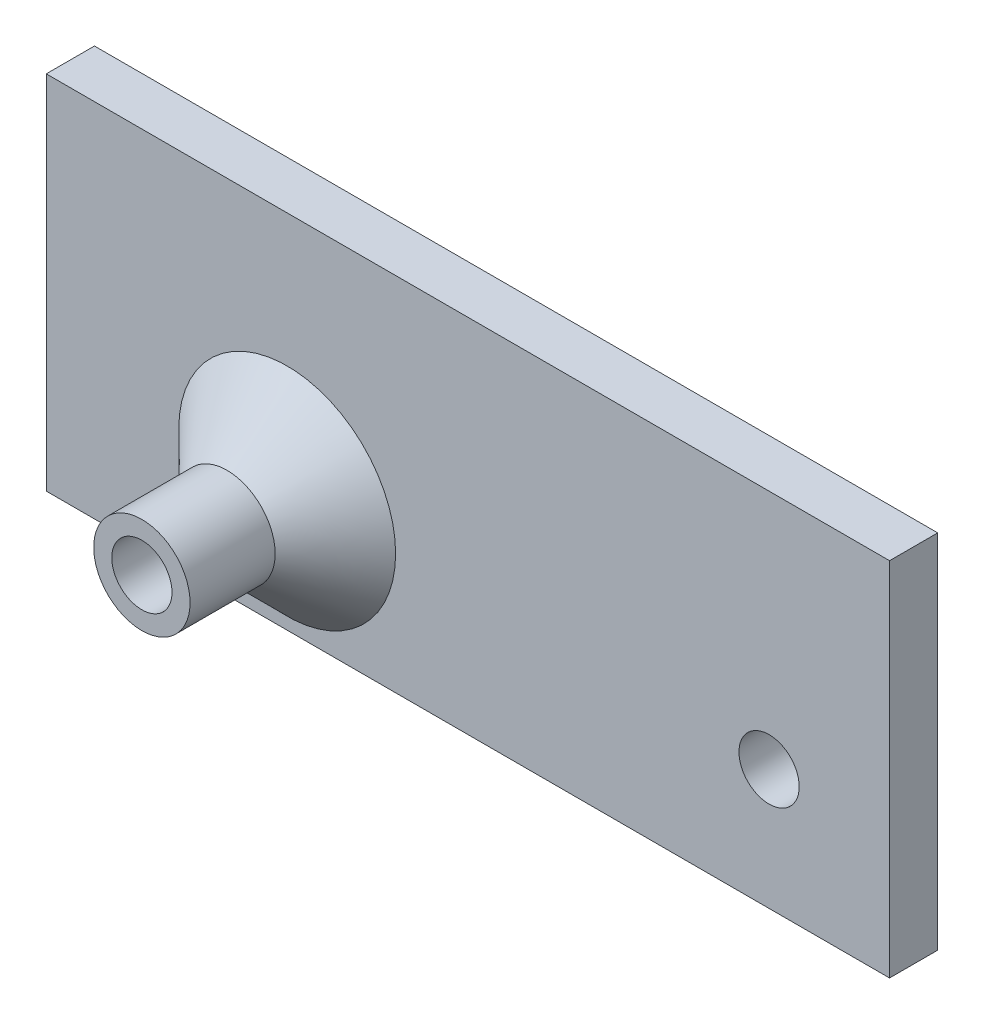
from build123d import *

# Parameters (mm, degrees)
SKETCH1_W           = 70
SKETCH1_H           = 30
SKETCH1_R           = 4
SKETCH1_R_2         = 2.5
BOSS_EXTRUDE1_DEPTH = 4
SKETCH1_3_R         = 4
SKETCH1_3_R_2       = 2.5
BOSS_EXTRUDE2_DEPTH = 16.063
CHAMFER1_SIZE       = 5


with BuildPart() as part:
    # Sketch1 → Boss-Extrude1 (new body)
    with BuildSketch(Plane.XY):
        with Locations((15, 5)):
            Rectangle(SKETCH1_W, SKETCH1_H)
        Circle(SKETCH1_R, mode=Mode.SUBTRACT)
        with Locations((40, 0)):
            Circle(SKETCH1_R_2, mode=Mode.SUBTRACT)
    extrude(amount=BOSS_EXTRUDE1_DEPTH)

    # Sketch1_3 → Boss-Extrude2 (add)
    with BuildSketch(Plane.XY):
        Circle(SKETCH1_3_R)
        Circle(SKETCH1_3_R_2, mode=Mode.SUBTRACT)
    extrude(amount=BOSS_EXTRUDE2_DEPTH)

    # Chamfer1
    chamfer1_edges = [part.edges().sort_by_distance(p)[0] for p in [
        (-4, 0, 4),
    ]]
    chamfer(chamfer1_edges, length=CHAMFER1_SIZE)


solid = part.part
